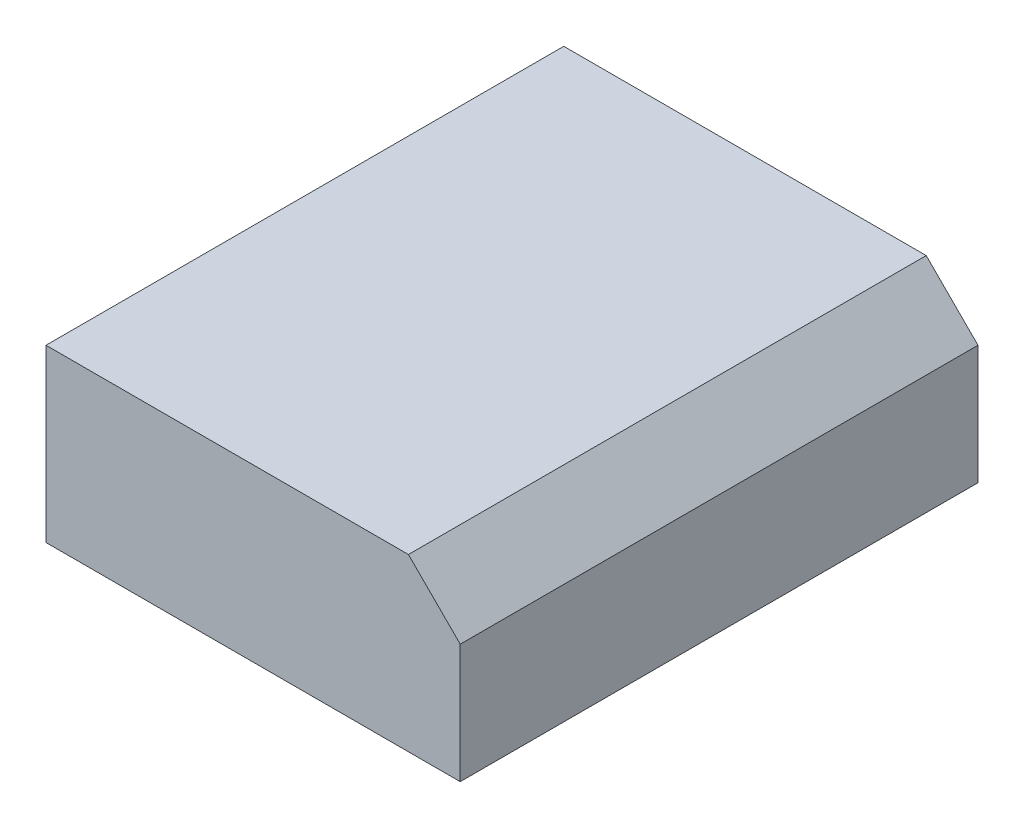
from build123d import *

# Parameters (mm, degrees)
EXTRUDE_START   = 0.1
SKETCH_1_W      = 4
SKETCH_1_H      = 5
EXTRUDE_1_DEPTH = 1.65
CHAMFER_1_SIZE  = 0.5
SKETCH_2_W      = 2.41
SKETCH_2_H      = 3.1
EXTRUDE_2_DEPTH = 0.1


with BuildPart() as part:
    # Эскиз1 → Бобышка-Вытянуть1 (new body)
    with BuildSketch(Plane(origin=(0, 0, 0), x_dir=(1, 0, 0), z_dir=(0, 1, 0)).offset(EXTRUDE_START)):
        Rectangle(SKETCH_1_W, SKETCH_1_H)
    extrude(amount=EXTRUDE_1_DEPTH)

    # Фаска1
    chamfer_1_edges = [part.edges().sort_by_distance(p)[0] for p in [
        (2, 1.75, 0),
    ]]
    chamfer(chamfer_1_edges, length=CHAMFER_1_SIZE)


with BuildPart() as body_2:
    # Эскиз2 → Бобышка-Вытянуть2 (new body)
    with BuildSketch(Plane(origin=(0, 0, 0), x_dir=(1, 0, 0), z_dir=(0, 1, 0))):
        Rectangle(SKETCH_2_W, SKETCH_2_H)
    extrude(amount=EXTRUDE_2_DEPTH)


solid = Compound([part.part, body_2.part])
